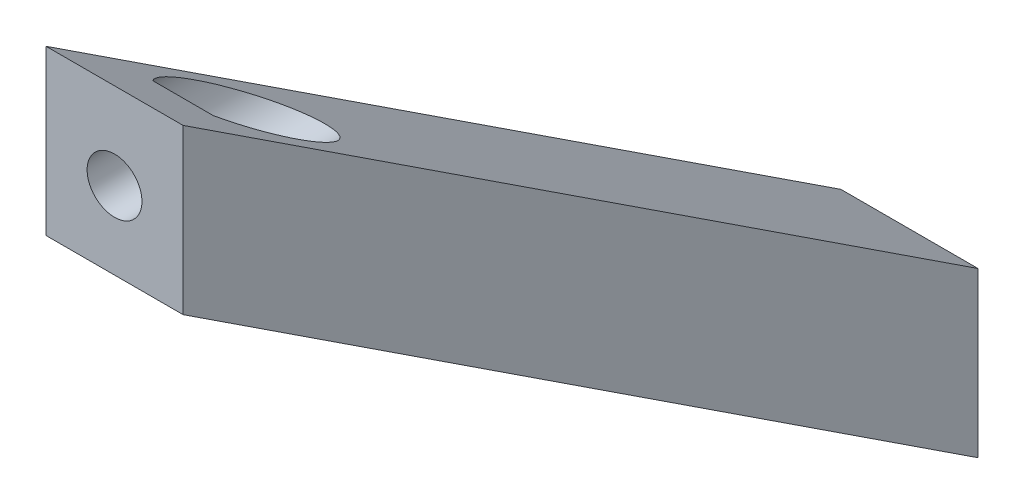
from build123d import *

# Parameters (mm, degrees)
BOSS_EXTRUDE1_DEPTH = 20
SKETCH2_R           = 4
CUT_EXTRUDE5_DEPTH  = 117
CUT_EXTRUDE6_START  = -10
SKETCH5_R           = 7.5
CUT_EXTRUDE6_DEPTH  = 107
SKETCH6_R           = 4
CUT_EXTRUDE7_DEPTH  = 117
CUT_EXTRUDE8_START  = -10
SKETCH7_R           = 7.5
CUT_EXTRUDE8_DEPTH  = 107


with BuildPart() as part:
    # Sketch1 → Boss-Extrude1 (new body)
    with BuildSketch(Plane(origin=(0, 0, 0), x_dir=(0, 0, -1), z_dir=(1, 0, 0))):
        Polygon((116, 48.213061677), (0, 124.295055109), (0, 100.377048541), (116, 24.295055109), align=None)
    extrude(amount=BOSS_EXTRUDE1_DEPTH)

    # Sketch2 → Cut-Extrude5 (cut, through all)
    with BuildSketch(Plane.XY):
        with Locations((10, 111.680172571)):
            Circle(SKETCH2_R)
    extrude(amount=-CUT_EXTRUDE5_DEPTH, mode=Mode.SUBTRACT)

    # Sketch5 → Cut-Extrude6 (cut, through all)
    with BuildSketch(Plane.XY.offset(CUT_EXTRUDE6_START)):
        with Locations((10, 111.680172571)):
            Circle(SKETCH5_R)
    extrude(amount=-CUT_EXTRUDE6_DEPTH, mode=Mode.SUBTRACT)

    # Sketch6 → Cut-Extrude7 (cut, through all)
    with BuildSketch(Plane(origin=(0, 0, -116), x_dir=(-1, 0, 0), z_dir=(0, 0, -1))):
        with Locations((-10, 36.909937646)):
            Circle(SKETCH6_R)
    extrude(amount=-CUT_EXTRUDE7_DEPTH, mode=Mode.SUBTRACT)

    # Sketch7 → Cut-Extrude8 (cut, through all)
    with BuildSketch(Plane(origin=(0, 0, -116), x_dir=(-1, 0, 0), z_dir=(0, 0, -1)).offset(CUT_EXTRUDE8_START)):
        with Locations((-10, 36.909937646)):
            Circle(SKETCH7_R)
    extrude(amount=-CUT_EXTRUDE8_DEPTH, mode=Mode.SUBTRACT)


solid = part.part
